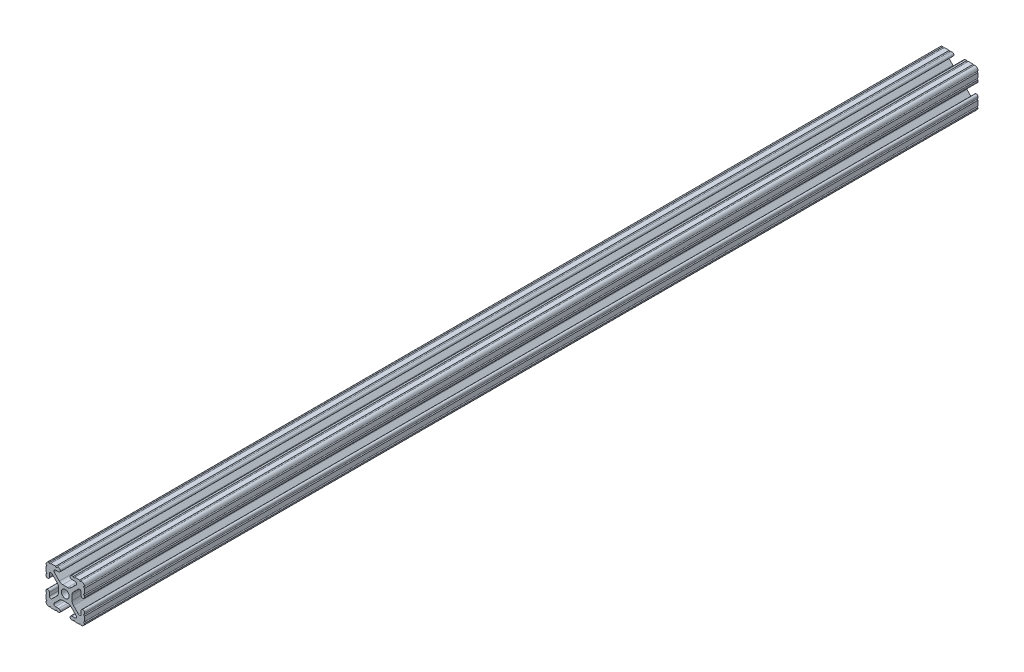
from build123d import *

# Parameters (mm, degrees)
SKETCH1_R           = 2.6035
BOSS_EXTRUDE1_DEPTH = 590.55


with BuildPart() as part:
    # Sketch1 → Boss-Extrude1 (new body)
    with BuildSketch(Plane.XY.offset(590.55)):
        with BuildLine():
            Line((-12.7, -6.3330836), (-12.7, -9.5504))
            ThreePointArc((-12.7, -9.5504), (-12.192000006, -10.058323491), (-12.699846982, -10.566399977))
            ThreePointArc((-12.699846982, -10.566399977), (-12.082522516, -12.082522516), (-10.566399977, -12.699846982))
            ThreePointArc((-10.566399977, -12.699846982), (-10.058323491, -12.192000006), (-9.5504, -12.7))
            Line((-9.5504, -12.7), (-6.3330836, -12.7))
            ThreePointArc((-6.3330836, -12.7), (-5.8250836, -12.192), (-5.3170836, -12.7))
            Line((-5.3170836, -12.7), (-4.343399971, -12.7))
            ThreePointArc((-4.343399971, -12.7), (-3.238499971, -11.5951), (-4.343399971, -10.4902))
            Line((-4.343399971, -10.4902), (-6.474794456, -10.4902))
            ThreePointArc((-6.474794456, -10.4902), (-7.413456061, -9.863006367), (-7.193214945, -8.75577951))
            Line((-7.193214945, -8.75577951), (-3.863171405, -5.42573597))
            ThreePointArc((-3.863171405, -5.42573597), (-2.833127272, -4.737482484), (-1.618107374, -4.4958))
            Line((-1.618107374, -4.4958), (1.618107374, -4.4958))
            ThreePointArc((1.618107374, -4.4958), (2.833127272, -4.737482484), (3.863171405, -5.42573597))
            Line((3.863171405, -5.42573597), (7.193214945, -8.75577951))
            ThreePointArc((7.193214945, -8.75577951), (7.413456061, -9.863006367), (6.474794456, -10.4902))
            Line((6.474794456, -10.4902), (4.3434, -10.4902))
            ThreePointArc((4.3434, -10.4902), (3.2385, -11.5951), (4.3434, -12.7))
            Line((4.3434, -12.7), (5.3170836, -12.7))
            ThreePointArc((5.3170836, -12.7), (5.8250836, -12.192), (6.3330836, -12.7))
            Line((6.3330836, -12.7), (9.5504, -12.7))
            ThreePointArc((9.5504, -12.7), (10.058323491, -12.192000006), (10.566399977, -12.699846982))
            ThreePointArc((10.566399977, -12.699846982), (12.082522516, -12.082522516), (12.699846982, -10.566399977))
            ThreePointArc((12.699846982, -10.566399977), (12.192000006, -10.058323491), (12.7, -9.5504))
            Line((12.7, -9.5504), (12.7, -6.3330836))
            ThreePointArc((12.7, -6.3330836), (12.192, -5.8250836), (12.7, -5.3170836))
            Line((12.7, -5.3170836), (12.7, -4.343399971))
            ThreePointArc((12.7, -4.343399971), (11.5951, -3.238499971), (10.4902, -4.343399971))
            Line((10.4902, -4.343399971), (10.4902, -6.474794456))
            ThreePointArc((10.4902, -6.474794456), (9.863006367, -7.413456061), (8.75577951, -7.193214945))
            Line((8.75577951, -7.193214945), (5.42573597, -3.863171405))
            ThreePointArc((5.42573597, -3.863171405), (4.737482484, -2.833127272), (4.4958, -1.618107374))
            Line((4.4958, -1.618107374), (4.4958, 1.618107374))
            ThreePointArc((4.4958, 1.618107374), (4.737482484, 2.833127272), (5.42573597, 3.863171405))
            Line((5.42573597, 3.863171405), (8.75577951, 7.193214945))
            ThreePointArc((8.75577951, 7.193214945), (9.863006367, 7.413456061), (10.4902, 6.474794456))
            Line((10.4902, 6.474794456), (10.4902, 4.3434))
            ThreePointArc((10.4902, 4.3434), (11.5951, 3.2385), (12.7, 4.3434))
            Line((12.7, 4.3434), (12.7, 5.3170836))
            ThreePointArc((12.7, 5.3170836), (12.192, 5.8250836), (12.7, 6.3330836))
            Line((12.7, 6.3330836), (12.7, 9.5504))
            ThreePointArc((12.7, 9.5504), (12.192000006, 10.058323491), (12.699846982, 10.566399977))
            ThreePointArc((12.699846982, 10.566399977), (12.082522516, 12.082522516), (10.566399977, 12.699846982))
            ThreePointArc((10.566399977, 12.699846982), (10.058323491, 12.192000006), (9.5504, 12.7))
            Line((9.5504, 12.7), (6.3330836, 12.7))
            ThreePointArc((6.3330836, 12.7), (5.8250836, 12.192), (5.3170836, 12.7))
            Line((5.3170836, 12.7), (4.343399971, 12.7))
            ThreePointArc((4.343399971, 12.7), (3.238499971, 11.5951), (4.343399971, 10.4902))
            Line((4.343399971, 10.4902), (6.474794456, 10.4902))
            ThreePointArc((6.474794456, 10.4902), (7.413456061, 9.863006367), (7.193214945, 8.75577951))
            Line((7.193214945, 8.75577951), (3.863171405, 5.42573597))
            ThreePointArc((3.863171405, 5.42573597), (2.833127272, 4.737482484), (1.618107374, 4.4958))
            Line((1.618107374, 4.4958), (-1.618107374, 4.4958))
            ThreePointArc((-1.618107374, 4.4958), (-2.833127272, 4.737482484), (-3.863171405, 5.42573597))
            Line((-3.863171405, 5.42573597), (-7.193214945, 8.75577951))
            ThreePointArc((-7.193214945, 8.75577951), (-7.413456061, 9.863006367), (-6.474794456, 10.4902))
            Line((-6.474794456, 10.4902), (-4.3434, 10.4902))
            ThreePointArc((-4.3434, 10.4902), (-3.2385, 11.5951), (-4.3434, 12.7))
            Line((-4.3434, 12.7), (-5.3170836, 12.7))
            ThreePointArc((-5.3170836, 12.7), (-5.8250836, 12.192), (-6.3330836, 12.7))
            Line((-6.3330836, 12.7), (-9.5504, 12.7))
            ThreePointArc((-9.5504, 12.7), (-10.058323491, 12.192000006), (-10.566399977, 12.699846982))
            ThreePointArc((-10.566399977, 12.699846982), (-12.082522516, 12.082522516), (-12.699846982, 10.566399977))
            ThreePointArc((-12.699846982, 10.566399977), (-12.192000006, 10.058323491), (-12.7, 9.5504))
            Line((-12.7, 9.5504), (-12.7, 6.3330836))
            ThreePointArc((-12.7, 6.3330836), (-12.192, 5.8250836), (-12.7, 5.3170836))
            Line((-12.7, 5.3170836), (-12.7, 4.343399971))
            ThreePointArc((-12.7, 4.343399971), (-11.5951, 3.238499971), (-10.4902, 4.343399971))
            Line((-10.4902, 4.343399971), (-10.4902, 6.474794456))
            ThreePointArc((-10.4902, 6.474794456), (-9.863006367, 7.413456061), (-8.75577951, 7.193214945))
            Line((-8.75577951, 7.193214945), (-5.42573597, 3.863171405))
            ThreePointArc((-5.42573597, 3.863171405), (-4.737482484, 2.833127272), (-4.4958, 1.618107374))
            Line((-4.4958, 1.618107374), (-4.4958, -1.618107374))
            ThreePointArc((-4.4958, -1.618107374), (-4.737482484, -2.833127272), (-5.42573597, -3.863171405))
            Line((-5.42573597, -3.863171405), (-8.75577951, -7.193214945))
            ThreePointArc((-8.75577951, -7.193214945), (-9.863006367, -7.413456061), (-10.4902, -6.474794456))
            Line((-10.4902, -6.474794456), (-10.4902, -4.3434))
            ThreePointArc((-10.4902, -4.3434), (-11.5951, -3.2385), (-12.7, -4.3434))
            Line((-12.7, -4.3434), (-12.7, -5.3170836))
            ThreePointArc((-12.7, -5.3170836), (-12.192, -5.8250836), (-12.7, -6.3330836))
        make_face()
        Circle(SKETCH1_R, mode=Mode.SUBTRACT)
    extrude(amount=-BOSS_EXTRUDE1_DEPTH)


solid = part.part
